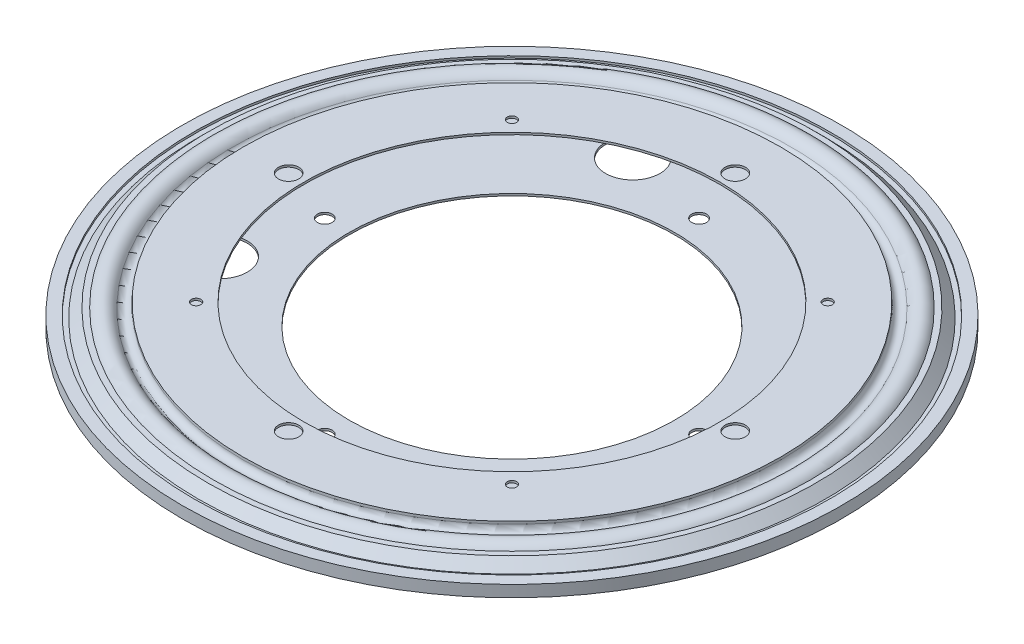
from build123d import *

# Parameters (mm, degrees)
CIRPATTERN1_COUNT  = 9
SKETCH3_R          = 9.525
CUT_EXTRUDE1_DEPTH = 1.7366001
SKETCH4_W          = 3.571875
SKETCH4_H          = 0.7376
CIRPATTERN2_COUNT  = 4
CIRPATTERN3_COUNT  = 4
SKETCH8_W          = 1.651
SKETCH8_H          = 0.7376
CIRPATTERN4_COUNT  = 4


with BuildPart() as part:
    # Sketch1 → Revolve-Thin1 (revolve)
    with BuildSketch(Plane.XY):
        with BuildLine():
            Line((111.6965, 0), (115.7605, 0))
            Line((115.7605, 0), (115.7605, -4.064))
            Line((115.7605, -4.064), (108.835901517, -4.064))
            Line((108.835901517, -4.064), (108.835901517, -3.175))
            ThreePointArc((108.835901517, -3.175), (107.35355961, -1.218753599), (105.069267678, -2.116666667))
            ThreePointArc((105.069267678, -2.116666667), (101.6, -4.064), (98.130732322, -2.116666667))
            ThreePointArc((98.130732322, -2.116666667), (95.84644039, -1.218753599), (94.364098483, -3.175))
            Line((94.364098483, -3.175), (94.364098483, -4.064))
            Line((94.364098483, -4.064), (57.15, -4.064))
            Line((57.15, -4.064), (57.15, -3.3274))
            Line((57.15, -3.3274), (93.627498483, -3.3274))
            Line((93.627498483, -3.3274), (93.627498483, -3.175))
            ThreePointArc((93.627498483, -3.175), (95.647189331, -0.509614279), (98.759537089, -1.733020833))
            ThreePointArc((98.759537089, -1.733020833), (101.6, -3.3274), (104.440462911, -1.733020833))
            ThreePointArc((104.440462911, -1.733020833), (107.552810669, -0.509614279), (109.572501517, -3.175))
            Line((109.572501517, -3.175), (109.572501517, -3.3274))
            Line((109.572501517, -3.3274), (115.0239, -3.3274))
            Line((115.0239, -3.3274), (115.0239, -0.7366))
            Line((115.0239, -0.7366), (111.6965, -0.7366))
            Line((111.6965, -0.7366), (111.6965, 0))
        make_face()
    revolve(axis=Axis((0, 21.71272626, 0), (0, -1, 0)))

    # Sketch3 → Cut-Extrude1 (cut, through all)
    with BuildSketch(Plane(origin=(0, -3.3274, 0), x_dir=(-1, 0, 0), z_dir=(0, 1, 0))):
        with Locations((30.015851554, -72.464675908)):
            Circle(SKETCH3_R)
        with Locations((-72.464675908, -30.015851554)):
            Circle(SKETCH3_R)
        with Locations((-30.015851554, 72.464675908)):
            Circle(SKETCH3_R)
        with Locations((72.464675908, 30.015851554)):
            Circle(SKETCH3_R)
    extrude(amount=-CUT_EXTRUDE1_DEPTH, mode=Mode.SUBTRACT)

    # Sketch6 → 13_64 _0.203130_ Diameter Hole1 (revolve, cut)
    with BuildSketch(Plane(origin=(0, -3.3274, -65.7352), x_dir=(0, 0, 1), z_dir=(1, 0, 0))):
        Polygon((0, 0), (0, 9.678070783), (2.579751, 8.128), (2.579751, 0), align=None)
    f_13_64_0_203130_diameter_hole1 = revolve(axis=Axis((0, 3.0226, -65.7352), (0, -1, 0)), mode=Mode.SUBTRACT)

    # CirPattern3: 13_64 _0.203130_ Diameter Hole1 ×4 about axis
    cirpattern3_axis = Axis((0, 0, 0), (0, 1, 0))
    for i in range(1, CIRPATTERN3_COUNT):
        add(f_13_64_0_203130_diameter_hole1.rotate(cirpattern3_axis, i * 360 / CIRPATTERN3_COUNT), mode=Mode.SUBTRACT)


with BuildPart() as body_2:
    # Sketch1_7 → Revolve-Thin2 (revolve)
    with BuildSketch(Plane.XY):
        with BuildLine():
            Line((113.7285, -0.889), (110.085660312, -0.889))
            Line((110.085660312, -0.889), (106.803901517, 2.392758795))
            Line((106.803901517, 2.392758795), (104.884935517, 2.392758795))
            ThreePointArc((104.884935517, 2.392758795), (101.43401415, 4.060608907), (98.130732322, 2.116666667))
            ThreePointArc((98.130732322, 2.116666667), (95.84644039, 1.218753599), (94.364098483, 3.175))
            Line((94.364098483, 3.175), (94.364098483, 4.064))
            Line((94.364098483, 4.064), (73.025, 4.064))
            Line((73.025, 4.064), (73.025, 3.3274))
            Line((73.025, 3.3274), (93.627498483, 3.3274))
            Line((93.627498483, 3.3274), (93.627498483, 3.175))
            ThreePointArc((93.627498483, 3.175), (95.647189331, 0.509614279), (98.759537089, 1.733020833))
            ThreePointArc((98.759537089, 1.733020833), (101.644657546, 3.327100309), (104.485953708, 1.656158795))
            Line((104.485953708, 1.656158795), (106.498791807, 1.656158795))
            Line((106.498791807, 1.656158795), (109.780550602, -1.6256))
            Line((109.780550602, -1.6256), (113.7285, -1.6256))
            Line((113.7285, -1.6256), (113.7285, -0.889))
        make_face()
    revolve(axis=Axis((0, 21.71272626, 0), (0, -1, 0)))

    # Sketch4 → 9_32 _0.281250_ Diameter Hole1 (revolve, cut)
    with BuildSketch(Plane(origin=(0, 4.064, -78.4352), x_dir=(0, 0, 1), z_dir=(1, 0, 0))):
        with Locations((1.7859375, 0.3688)):
            Rectangle(SKETCH4_W, SKETCH4_H)
    f_9_32_0_281250_diameter_hole1 = revolve(axis=Axis((0, 10.414, -78.4352), (0, -1, 0)), mode=Mode.SUBTRACT)

    # CirPattern2: 9_32 _0.281250_ Diameter Hole1 ×4 about axis
    cirpattern2_axis = Axis((0, 0, 0), (0, 1, 0))
    for i in range(1, CIRPATTERN2_COUNT):
        add(f_9_32_0_281250_diameter_hole1.rotate(cirpattern2_axis, i * 360 / CIRPATTERN2_COUNT), mode=Mode.SUBTRACT)

    # Sketch8 → 97 _0.005900_ Diameter Hole1 (revolve, cut)
    with BuildSketch(Plane(origin=(-55.462061804, 4.064, 55.462061804), x_dir=(0, 0, 1), z_dir=(1, 0, 0))):
        with Locations((0.8255, 0.3688)):
            Rectangle(SKETCH8_W, SKETCH8_H)
    f_97_0_005900_diameter_hole1 = revolve(axis=Axis((-55.462061804, 10.414, 55.462061804), (0, -1, 0)), mode=Mode.SUBTRACT)

    # CirPattern4: 97 _0.005900_ Diameter Hole1 ×4 about axis
    cirpattern4_axis = Axis((0, 0, 0), (0, 1, 0))
    for i in range(1, CIRPATTERN4_COUNT):
        add(f_97_0_005900_diameter_hole1.rotate(cirpattern4_axis, i * 360 / CIRPATTERN4_COUNT), mode=Mode.SUBTRACT)


with BuildPart() as body_3:
    # Sketch2 → Revolve1 (revolve)
    with BuildSketch(Plane.XY):
        with BuildLine():
            Line((101.6, 3.2766), (101.6, -3.2766))
            ThreePointArc((101.6, -3.2766), (104.8766, 0), (101.6, 3.2766))
        make_face()
    revolve(axis=Axis((101.6, 5.355428419, 0), (0, -1, 0)))


with BuildPart() as cirpattern1_1:
    # CirPattern1: pattern copy
    add(body_3.part.rotate(Axis((0, 0, 0), (0, 1, 0)), 1 * 360 / CIRPATTERN1_COUNT))


with BuildPart() as cirpattern1_2:
    # CirPattern1: pattern copy
    add(body_3.part.rotate(Axis((0, 0, 0), (0, 1, 0)), 2 * 360 / CIRPATTERN1_COUNT))


with BuildPart() as cirpattern1_3:
    # CirPattern1: pattern copy
    add(body_3.part.rotate(Axis((0, 0, 0), (0, 1, 0)), 3 * 360 / CIRPATTERN1_COUNT))


with BuildPart() as cirpattern1_4:
    # CirPattern1: pattern copy
    add(body_3.part.rotate(Axis((0, 0, 0), (0, 1, 0)), 4 * 360 / CIRPATTERN1_COUNT))


with BuildPart() as cirpattern1_5:
    # CirPattern1: pattern copy
    add(body_3.part.rotate(Axis((0, 0, 0), (0, 1, 0)), 5 * 360 / CIRPATTERN1_COUNT))


with BuildPart() as cirpattern1_6:
    # CirPattern1: pattern copy
    add(body_3.part.rotate(Axis((0, 0, 0), (0, 1, 0)), 6 * 360 / CIRPATTERN1_COUNT))


with BuildPart() as cirpattern1_7:
    # CirPattern1: pattern copy
    add(body_3.part.rotate(Axis((0, 0, 0), (0, 1, 0)), 7 * 360 / CIRPATTERN1_COUNT))


with BuildPart() as cirpattern1_8:
    # CirPattern1: pattern copy
    add(body_3.part.rotate(Axis((0, 0, 0), (0, 1, 0)), 8 * 360 / CIRPATTERN1_COUNT))


solid = Compound([part.part, body_2.part, body_3.part, cirpattern1_1.part, cirpattern1_2.part, cirpattern1_3.part, cirpattern1_4.part, cirpattern1_5.part, cirpattern1_6.part, cirpattern1_7.part, cirpattern1_8.part])
